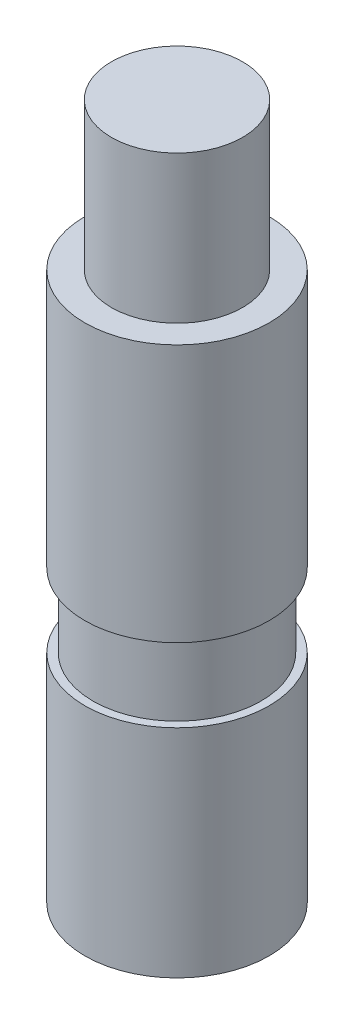
from build123d import *

# Parameters (mm, degrees)
SKETCH1_R           = 15.875
BOSS_EXTRUDE1_DEPTH = 119.888
SKETCH2_R           = 15.875
SKETCH2_R_2         = 11.303
CUT_EXTRUDE1_DEPTH  = 25.4
CUT_EXTRUDE2_START  = -69.85
SKETCH3_R           = 15.875
SKETCH3_R_2         = 14.478
CUT_EXTRUDE2_DEPTH  = 12.7


with BuildPart() as part:
    # Sketch1 → Boss-Extrude1 (new body)
    with BuildSketch(Plane(origin=(0, 0, 0), x_dir=(1, 0, 0), z_dir=(0, 1, 0))):
        Circle(SKETCH1_R)
    extrude(amount=BOSS_EXTRUDE1_DEPTH)

    # Sketch2 → Cut-Extrude1 (cut)
    with BuildSketch(Plane(origin=(0, 119.888, 0), x_dir=(1, 0, 0), z_dir=(0, 1, 0))):
        Circle(SKETCH2_R)
        Circle(SKETCH2_R_2, mode=Mode.SUBTRACT)
    extrude(amount=-CUT_EXTRUDE1_DEPTH, mode=Mode.SUBTRACT)

    # Sketch3 → Cut-Extrude2 (cut)
    with BuildSketch(Plane(origin=(0, 119.888, 0), x_dir=(1, 0, 0), z_dir=(0, 1, 0)).offset(CUT_EXTRUDE2_START)):
        Circle(SKETCH3_R)
        Circle(SKETCH3_R_2, mode=Mode.SUBTRACT)
    extrude(amount=-CUT_EXTRUDE2_DEPTH, mode=Mode.SUBTRACT)


solid = part.part
